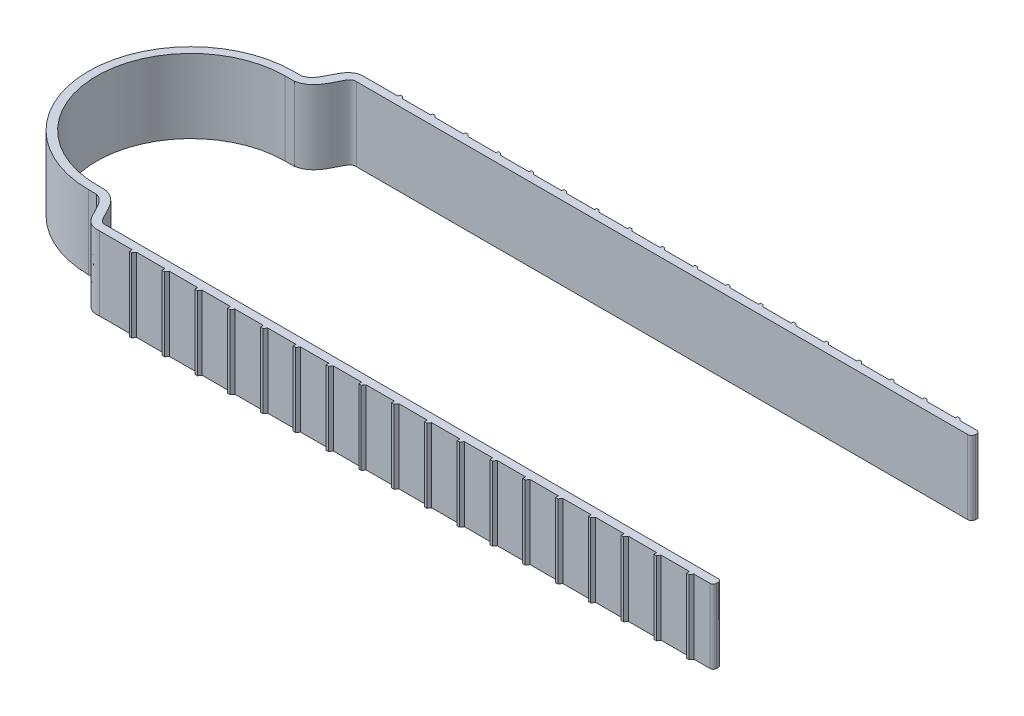
from build123d import *

# Parameters (mm, degrees)
BOSS_EXTRUDE1_DEPTH = 18


with BuildPart() as part:
    # Sketch1 → Boss-Extrude1 (new body)
    with BuildSketch(Plane(origin=(0, 0, 0), x_dir=(1, 0, 0), z_dir=(0, 1, 0))):
        with BuildLine():
            Line((0, -25), (1.941802817, -25.02220533))
            add(Edge.make_bspline(
                [(1.941802817, -25.02220533), (2.69451304, -25.199398418), (4.583645406, -26.500849824), (5.86287196, -30.816766087), (8.252463798, -32.591061023), (10.049383812, -32.38664971)],
                knots=[0.122516909, 0.122516909, 0.122516909, 0.122516909, 0.292834345, 0.695813035, 1, 1, 1, 1], degree=3))
            Line((10.049383812, -32.38664971), (18.049383812, -32.38664971))
            Line((18.049383812, -32.38664971), (18.049383812, -33.08664971))
            Line((18.049383812, -33.08664971), (18.647402706, -33.08664971))
            Line((18.647402706, -33.08664971), (19.147402706, -32.38664971))
            Line((19.147402706, -32.38664971), (26.049383812, -32.38664971))
            Line((26.049383812, -32.38664971), (26.049383812, -33.08664971))
            Line((26.049383812, -33.08664971), (26.647402706, -33.08664971))
            Line((26.647402706, -33.08664971), (27.147402706, -32.38664971))
            Line((27.147402706, -32.38664971), (34.049383812, -32.38664971))
            Line((34.049383812, -32.38664971), (34.049383812, -33.08664971))
            Line((34.049383812, -33.08664971), (34.647402706, -33.08664971))
            Line((34.647402706, -33.08664971), (35.147402706, -32.38664971))
            Line((35.147402706, -32.38664971), (42.049383812, -32.38664971))
            Line((42.049383812, -32.38664971), (42.049383812, -33.08664971))
            Line((42.049383812, -33.08664971), (42.647402706, -33.08664971))
            Line((42.647402706, -33.08664971), (43.147402706, -32.38664971))
            Line((43.147402706, -32.38664971), (50.049383812, -32.38664971))
            Line((50.049383812, -32.38664971), (50.049383812, -33.08664971))
            Line((50.049383812, -33.08664971), (50.647402706, -33.08664971))
            Line((50.647402706, -33.08664971), (51.147402706, -32.38664971))
            Line((51.147402706, -32.38664971), (58.049383812, -32.38664971))
            Line((58.049383812, -32.38664971), (58.049383812, -33.08664971))
            Line((58.049383812, -33.08664971), (58.647402706, -33.08664971))
            Line((58.647402706, -33.08664971), (59.147402706, -32.38664971))
            Line((59.147402706, -32.38664971), (66.049383812, -32.38664971))
            Line((66.049383812, -32.38664971), (66.049383812, -33.08664971))
            Line((66.049383812, -33.08664971), (66.647402706, -33.08664971))
            Line((66.647402706, -33.08664971), (67.147402706, -32.38664971))
            Line((67.147402706, -32.38664971), (74.049383812, -32.38664971))
            Line((74.049383812, -32.38664971), (74.049383812, -33.08664971))
            Line((74.049383812, -33.08664971), (74.647402706, -33.08664971))
            Line((74.647402706, -33.08664971), (75.147402706, -32.38664971))
            Line((75.147402706, -32.38664971), (82.049383812, -32.38664971))
            Line((82.049383812, -32.38664971), (82.049383812, -33.08664971))
            Line((82.049383812, -33.08664971), (82.647402706, -33.08664971))
            Line((82.647402706, -33.08664971), (83.147402706, -32.38664971))
            Line((83.147402706, -32.38664971), (90.049383812, -32.38664971))
            Line((90.049383812, -32.38664971), (90.049383812, -33.08664971))
            Line((90.049383812, -33.08664971), (90.647402706, -33.08664971))
            Line((90.647402706, -33.08664971), (91.147402706, -32.38664971))
            Line((91.147402706, -32.38664971), (98.049383812, -32.38664971))
            Line((98.049383812, -32.38664971), (98.049383812, -33.08664971))
            Line((98.049383812, -33.08664971), (98.647402706, -33.08664971))
            Line((98.647402706, -33.08664971), (99.147402706, -32.38664971))
            Line((99.147402706, -32.38664971), (106.049383812, -32.38664971))
            Line((106.049383812, -32.38664971), (106.049383812, -33.08664971))
            Line((106.049383812, -33.08664971), (106.647402706, -33.08664971))
            Line((106.647402706, -33.08664971), (107.147402706, -32.38664971))
            Line((107.147402706, -32.38664971), (114.049383812, -32.38664971))
            Line((114.049383812, -32.38664971), (114.049383812, -33.08664971))
            Line((114.049383812, -33.08664971), (114.647402706, -33.08664971))
            Line((114.647402706, -33.08664971), (115.147402706, -32.38664971))
            Line((115.147402706, -32.38664971), (122.049383812, -32.38664971))
            Line((122.049383812, -32.38664971), (122.049383812, -33.08664971))
            Line((122.049383812, -33.08664971), (122.647402706, -33.08664971))
            Line((122.647402706, -33.08664971), (123.147402706, -32.38664971))
            Line((123.147402706, -32.38664971), (130.049383812, -32.38664971))
            Line((130.049383812, -32.38664971), (130.049383812, -33.08664971))
            Line((130.049383812, -33.08664971), (130.647402706, -33.08664971))
            Line((130.647402706, -33.08664971), (131.147402706, -32.38664971))
            Line((131.147402706, -32.38664971), (138.049383812, -32.38664971))
            Line((138.049383812, -32.38664971), (138.049383812, -33.08664971))
            Line((138.049383812, -33.08664971), (138.647402706, -33.08664971))
            Line((138.647402706, -33.08664971), (139.147402706, -32.38664971))
            Line((139.147402706, -32.38664971), (146.049383812, -32.38664971))
            Line((146.049383812, -32.38664971), (146.049383812, -33.08664971))
            Line((146.049383812, -33.08664971), (146.647402706, -33.08664971))
            Line((146.647402706, -33.08664971), (147.147402706, -32.38664971))
            Line((147.147402706, -32.38664971), (154.049383812, -32.38664971))
            Line((154.049383812, -32.38664971), (154.049383812, -33.08664971))
            Line((154.049383812, -33.08664971), (154.647402706, -33.08664971))
            Line((154.647402706, -33.08664971), (155.147402706, -32.38664971))
            Line((155.147402706, -32.38664971), (159.049383812, -32.38664971))
            ThreePointArc((159.049383812, -32.38664971), (159.615069237, -32.152335135), (159.849383812, -31.58664971))
            Line((159.849383812, -31.58664971), (159.849383812, -31.18664971))
            ThreePointArc((159.849383812, -31.18664971), (159.615069237, -30.620964285), (159.049383812, -30.38664971))
            Line((159.049383812, -30.38664971), (9.935992978, -30.38664971))
            add(Edge.make_bspline(
                [(2.185308983, -23.024859161), (2.247460333, -23.03949001), (2.346321759, -23.062006286), (2.647261549, -23.136253232), (2.923898871, -23.223830247), (3.470085829, -23.42790302), (4.216853388, -23.837285512), (5.022611873, -24.528466653), (5.86119718, -25.531280276), (6.601465876, -26.821251534), (7.291356198, -28.260184055), (7.930528682, -29.442623854), (8.428629045, -30.038718723), (8.744339426, -30.260700748), (8.976455771, -30.363308578), (9.260428013, -30.417496686), (9.537954475, -30.422409717), (9.717945521, -30.410361225), (9.803110846, -30.401971151), (9.895881585, -30.391212641), (9.935992978, -30.38664971)],
                knots=[0.106317301, 0.106317301, 0.106317301, 0.106317301, 0.120380427, 0.134443553, 0.148506678, 0.162569804, 0.218822308, 0.275074811, 0.331327315, 0.443832322, 0.556337329, 0.668842336, 0.781347343, 0.837599846, 0.89385235, 0.950104853, 0.978231105, 0.992294231, 0.999325794, 1.006357357, 1.006357357, 1.006357357, 1.006357357], degree=3))
            Line((2.185308983, -23.024859161), (0.01119672, -22.999997275))
            ThreePointArc((0.01119672, -22.999997275), (-16.259496847, -16.267414124), (-23, 0))
            ThreePointArc((-23, 0), (-16.263455964, 16.26345597), (8e-09, 23))
            Line((8e-09, 23), (2.218978524, 23))
            add(Edge.make_bspline(
                [(2.218978524, 23), (2.281300782, 23.014671082), (2.385564969, 23.039433813), (2.481460684, 23.061426356), (2.721100403, 23.120167002), (2.970178237, 23.194575525), (3.382639147, 23.340907547), (3.864177952, 23.56092986), (4.574270281, 23.98382191), (5.323974279, 24.610279474), (6.251734969, 25.695893092), (7.03699547, 27.057862338), (7.72913955, 28.515737463), (8.337723474, 29.654262491), (8.771727327, 30.171295755), (9.01992227, 30.353200839), (9.19015975, 30.435202168), (9.394632769, 30.488580701), (9.621706674, 30.50671539), (9.753143025, 30.507596382), (9.83307201, 30.505135973), (9.867716354, 30.503525978), (9.915797338, 30.501034818), (9.935992978, 30.500000008)],
                knots=[0.101204543, 0.101204543, 0.101204543, 0.101204543, 0.115306341, 0.122357239, 0.129408138, 0.143509936, 0.157611733, 0.185815328, 0.214018923, 0.270426113, 0.326833303, 0.439647683, 0.552462064, 0.665276444, 0.778090824, 0.834498014, 0.890905204, 0.947312394, 0.975515989, 0.989617787, 0.996668685, 1.000194135, 1.003719584, 1.003719584, 1.003719584, 1.003719584], degree=3))
            Line((9.935992978, 30.500000008), (159.000000085, 30.500000008))
            ThreePointArc((159.000000085, 30.500000008), (159.707106866, 30.792893227), (160.000000085, 31.500000008))
            Line((160.000000085, 31.500000008), (160.000000085, 32.000000008))
            ThreePointArc((160.000000085, 32.000000008), (159.576403756, 32.40280735), (159.000000085, 32.500000008))
            Line((159.000000085, 32.500000008), (155.098018978, 32.500000008))
            Line((155.098018978, 32.500000008), (154.598018978, 33.000000008))
            Line((154.598018978, 33.000000008), (154.000000085, 33.000000008))
            Line((154.000000085, 33.000000008), (154.000000085, 32.5))
            Line((154.000000085, 32.5), (147.098018978, 32.5))
            Line((147.098018978, 32.5), (146.598018978, 33))
            Line((146.598018978, 33), (146.000000085, 33))
            Line((146.000000085, 33), (146.000000085, 32.5))
            Line((146.000000085, 32.5), (139.098018978, 32.5))
            Line((139.098018978, 32.5), (138.598018978, 33))
            Line((138.598018978, 33), (138.000000085, 33))
            Line((138.000000085, 33), (138.000000085, 32.5))
            Line((138.000000085, 32.5), (131.098018978, 32.5))
            Line((131.098018978, 32.5), (130.598018978, 33))
            Line((130.598018978, 33), (130.000000085, 33))
            Line((130.000000085, 33), (130.000000085, 32.5))
            Line((130.000000085, 32.5), (123.098018978, 32.5))
            Line((123.098018978, 32.5), (122.598018978, 33))
            Line((122.598018978, 33), (122.000000085, 33))
            Line((122.000000085, 33), (122.000000085, 32.5))
            Line((122.000000085, 32.5), (115.098018978, 32.5))
            Line((115.098018978, 32.5), (114.598018978, 33))
            Line((114.598018978, 33), (114.000000085, 33))
            Line((114.000000085, 33), (114.000000085, 32.5))
            Line((114.000000085, 32.5), (107.098018978, 32.5))
            Line((107.098018978, 32.5), (106.598018978, 33))
            Line((106.598018978, 33), (106.000000085, 33))
            Line((106.000000085, 33), (106.000000085, 32.5))
            Line((106.000000085, 32.5), (99.098018978, 32.5))
            Line((99.098018978, 32.5), (98.598018978, 33))
            Line((98.598018978, 33), (98.000000085, 33))
            Line((98.000000085, 33), (98.000000085, 32.5))
            Line((98.000000085, 32.5), (91.098018978, 32.5))
            Line((91.098018978, 32.5), (90.598018978, 33))
            Line((90.598018978, 33), (90.000000085, 33))
            Line((90.000000085, 33), (90.000000085, 32.5))
            Line((90.000000085, 32.5), (83.098018978, 32.5))
            Line((83.098018978, 32.5), (82.598018978, 33))
            Line((82.598018978, 33), (82.000000085, 33))
            Line((82.000000085, 33), (82.000000085, 32.5))
            Line((82.000000085, 32.5), (75.098018978, 32.5))
            Line((75.098018978, 32.5), (74.598018978, 33))
            Line((74.598018978, 33), (74.000000085, 33))
            Line((74.000000085, 33), (74.000000085, 32.5))
            Line((74.000000085, 32.5), (67.098018978, 32.5))
            Line((67.098018978, 32.5), (66.598018978, 33))
            Line((66.598018978, 33), (66.000000085, 33))
            Line((66.000000085, 33), (66.000000085, 32.5))
            Line((66.000000085, 32.5), (59.098018978, 32.5))
            Line((59.098018978, 32.5), (58.598018978, 33))
            Line((58.598018978, 33), (58.000000085, 33))
            Line((58.000000085, 33), (58.000000085, 32.5))
            Line((58.000000085, 32.5), (51.098018978, 32.5))
            Line((51.098018978, 32.5), (50.598018978, 33))
            Line((50.598018978, 33), (50.000000085, 33))
            Line((50.000000085, 33), (50.000000085, 32.5))
            Line((50.000000085, 32.5), (43.098018978, 32.5))
            Line((43.098018978, 32.5), (42.598018978, 33))
            Line((42.598018978, 33), (42.000000085, 33))
            Line((42.000000085, 33), (42.000000085, 32.5))
            Line((42.000000085, 32.5), (35.098018978, 32.5))
            Line((35.098018978, 32.5), (34.598018978, 33))
            Line((34.598018978, 33), (34.000000085, 33))
            Line((34.000000085, 33), (34.000000085, 32.5))
            Line((34.000000085, 32.5), (27.098018978, 32.5))
            Line((27.098018978, 32.5), (26.598018978, 33))
            Line((26.598018978, 33), (26.000000085, 33))
            Line((26.000000085, 33), (26.000000085, 32.5))
            Line((26.000000085, 32.5), (19.098018978, 32.5))
            Line((19.098018978, 32.5), (18.598018978, 33))
            Line((18.598018978, 33), (18.000000085, 33))
            Line((18.000000085, 33), (18.000000085, 32.5))
            Line((18.000000085, 32.5), (10.000000085, 32.5))
            add(Edge.make_bspline(
                [(1.928687549, 24.999999993), (2.681397772, 25.177193081), (4.61759437, 26.525850526), (5.843578454, 30.812690035), (8.257456222, 32.589286681), (10.000000085, 32.5)],
                knots=[0.122516909, 0.122516909, 0.122516909, 0.122516909, 0.292834345, 0.695813035, 1, 1, 1, 1], degree=3))
            Line((1.928687549, 24.999999993), (0, 25))
            ThreePointArc((0, 25), (-17.67766953, 17.67766953), (-25, 0))
            ThreePointArc((-25, 0), (-17.67766953, -17.67766953), (0, -25))
        make_face()
    extrude(amount=BOSS_EXTRUDE1_DEPTH)


solid = part.part
